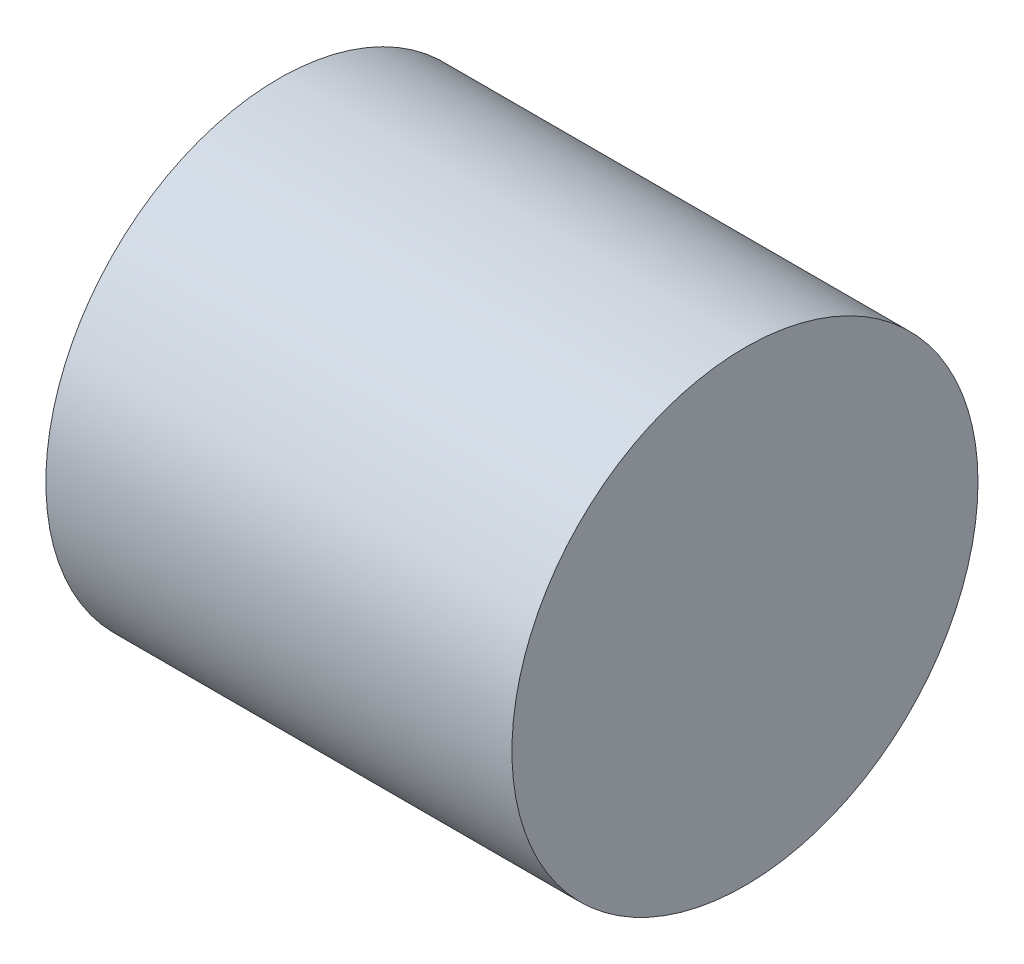
from build123d import *

# Parameters (mm, degrees)
SKETCH1_R           = 20
BOSS_EXTRUDE2_DEPTH = 40
SKETCH3_R           = 2
CUT_EXTRUDE1_DEPTH  = 5


with BuildPart() as part:
    # Sketch1 → Boss-Extrude2 (new body)
    with BuildSketch(Plane(origin=(0, 0, 0), x_dir=(0, 0, -1), z_dir=(1, 0, 0))):
        Circle(SKETCH1_R)
    extrude(amount=BOSS_EXTRUDE2_DEPTH)

    # Sketch3 → Cut-Extrude1 (cut)
    with BuildSketch(Plane.ZY):
        Circle(SKETCH3_R)
    extrude(amount=-CUT_EXTRUDE1_DEPTH, mode=Mode.SUBTRACT)


solid = part.part
